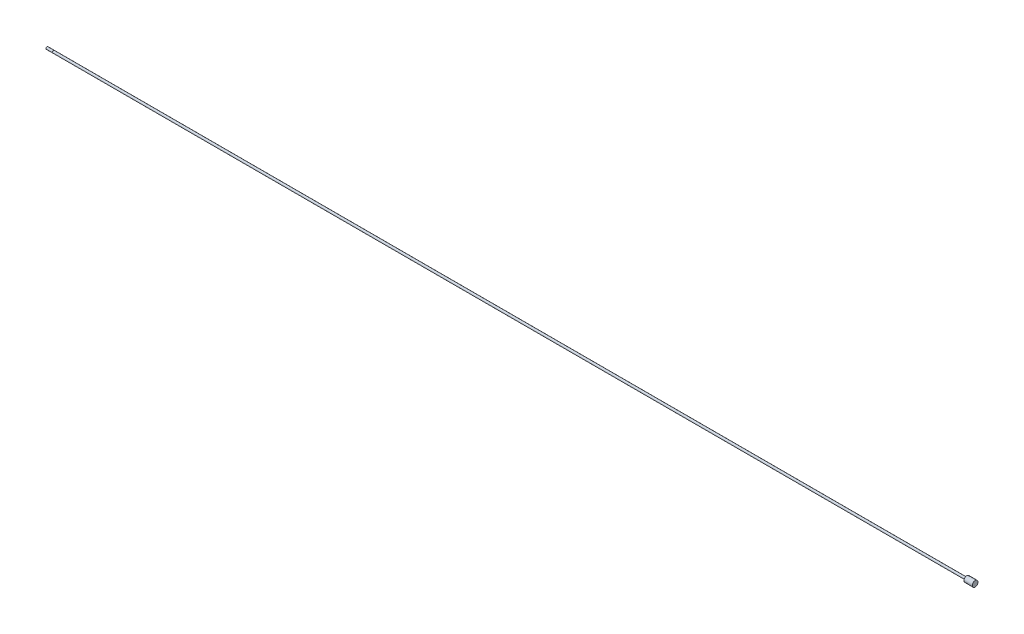
from build123d import *

# Parameters (mm, degrees)
SKETCH3_W = 0.254
SKETCH3_H = 0.508


with BuildPart() as part:
    # Sketch1 → Revolve1 (revolve)
    with BuildSketch(Plane.XY):
        Polygon((0, 0), (0, 1.5875), (1291.463, 1.5875), (1291.463, 4.03225), (1303.3248, 4.03225), (1303.3248, 0), align=None)
    revolve(axis=Axis((1303.3248, 0, 0), (-1, 0, 0)))

    # Sketch2 → Revolve2 (revolve)
    with BuildSketch(Plane.XY):
        Polygon((-9.652, 0), (-9.652, 1.20904), (-9.27354, 1.5875), (0, 1.5875), (0, 0), align=None)
    revolve(axis=Axis((0, 0, 0), (-1, 0, 0)))

    # Sketch3 → Cut-Revolve1 (revolve, cut)
    with BuildSketch(Plane.XY):
        with Locations((-0.127, 1.5875)):
            Rectangle(SKETCH3_W, SKETCH3_H)
    revolve(axis=Axis((0, 0, 0), (-1, 0, 0)), mode=Mode.SUBTRACT)


solid = part.part
